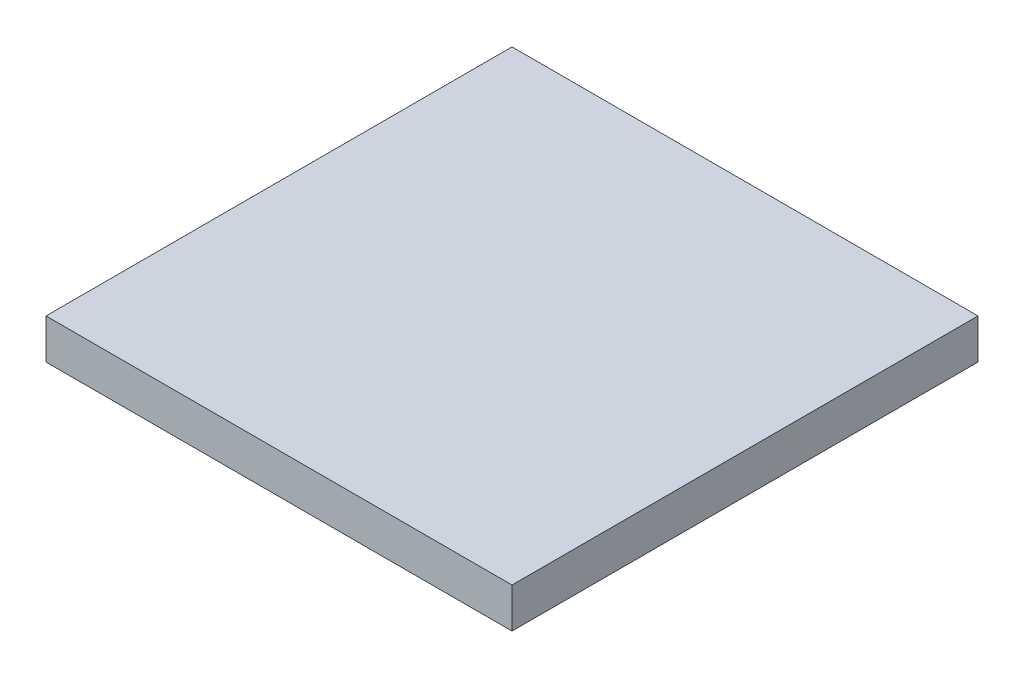
from build123d import *

# Parameters (mm, degrees)
SKETCH1_W           = 35
SKETCH1_H           = 35
BOSS_EXTRUDE1_DEPTH = 3


with BuildPart() as part:
    # Sketch1 → Boss-Extrude1 (new body)
    with BuildSketch(Plane(origin=(0, 0, 0), x_dir=(1, 0, 0), z_dir=(0, 1, 0))):
        Rectangle(SKETCH1_W, SKETCH1_H)
    extrude(amount=BOSS_EXTRUDE1_DEPTH)


solid = part.part
